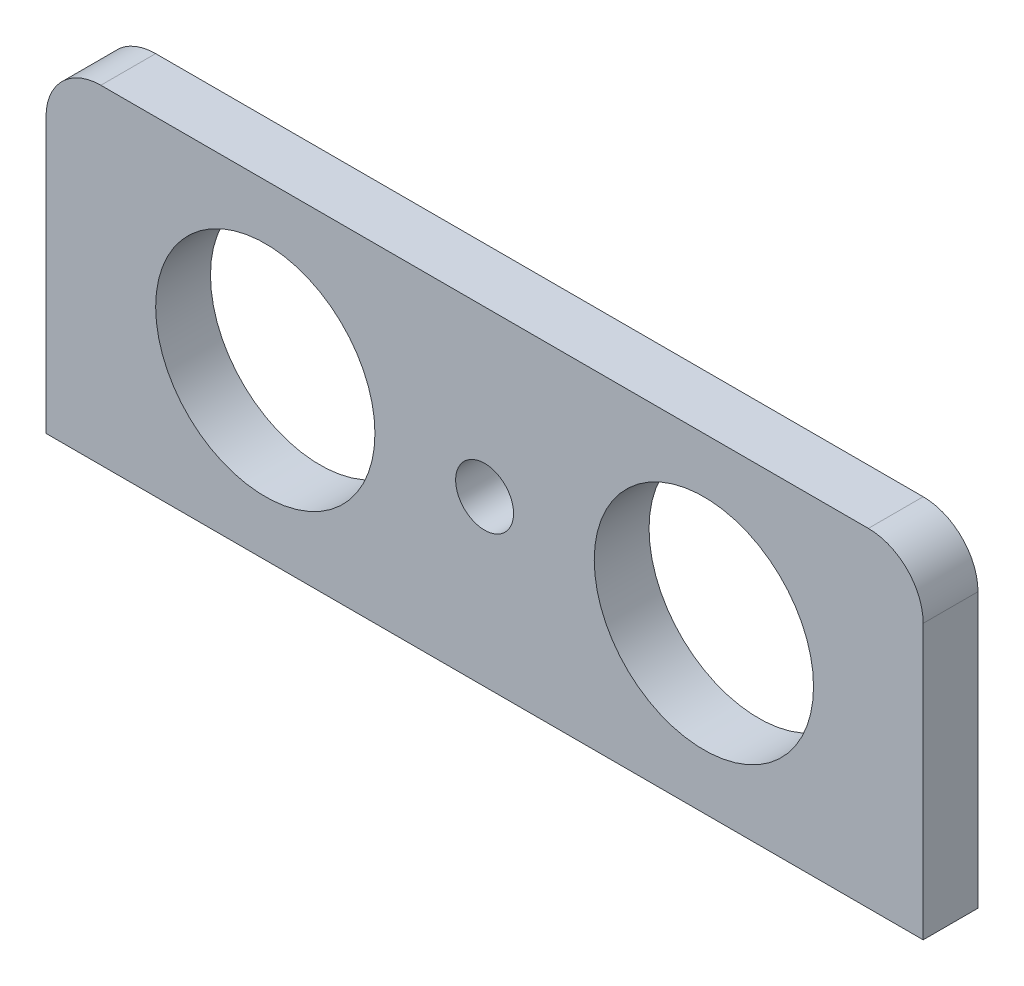
from build123d import *

# Parameters (mm, degrees)
SKETCH2_W           = 80
SKETCH2_H           = 30
SKETCH2_R           = 10
SKETCH2_R_2         = 2.641043536
BOSS_EXTRUDE1_DEPTH = 5
FILLET2_R           = 5


with BuildPart() as part:
    # Sketch2 → Boss-Extrude1 (new body)
    with BuildSketch(Plane.XY):
        with Locations((0.618817107, -21.917958992)):
            Rectangle(SKETCH2_W, SKETCH2_H)
        with Locations((-19.381182893, -21.917958992)):
            Circle(SKETCH2_R, mode=Mode.SUBTRACT)
        with Locations((20.618817107, -21.917958992)):
            Circle(SKETCH2_R, mode=Mode.SUBTRACT)
        with Locations((0.618817107, -21.917958992)):
            Circle(SKETCH2_R_2, mode=Mode.SUBTRACT)
    extrude(amount=BOSS_EXTRUDE1_DEPTH)

    # Fillet2
    fillet2_edges = [part.edges().sort_by_distance(p)[0] for p in [
        (-39.381182893, -6.917958992, 2.5),
        (40.618817107, -6.917958992, 2.5),
    ]]
    fillet(fillet2_edges, radius=FILLET2_R)


solid = part.part
